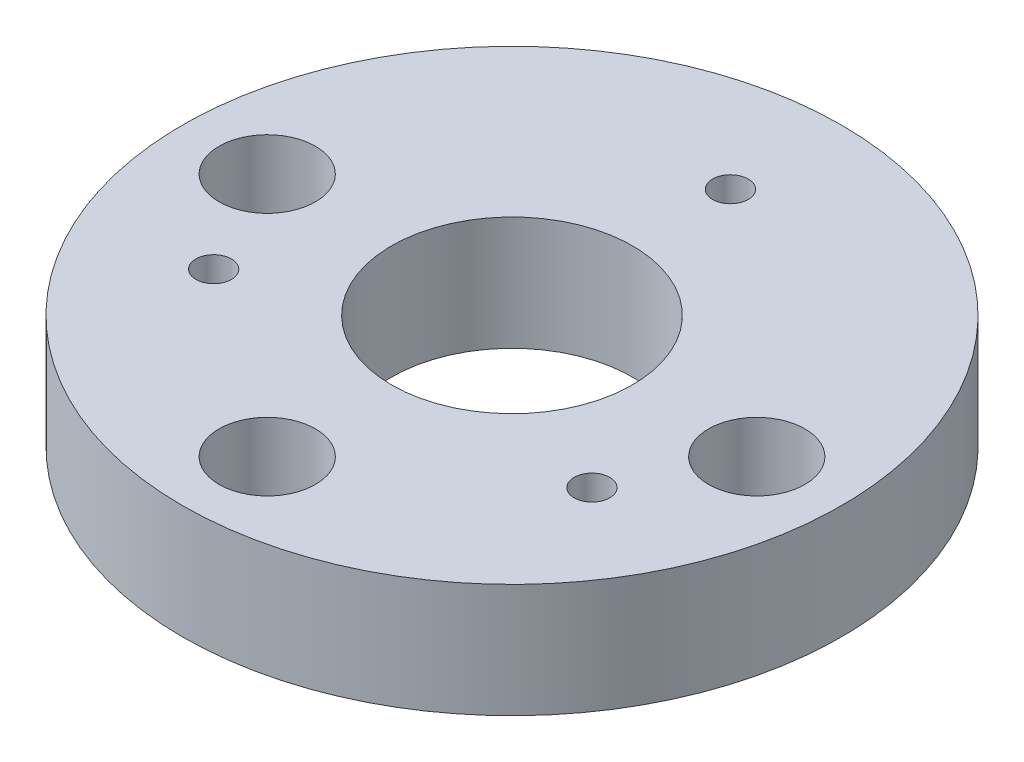
from build123d import *

# Parameters (mm, degrees)
SKETCH1_R               = 27.7876
SKETCH1_R_2             = 10.16
RING_DEPTH              = 9.5885
SKETCH2_R               = 1.5
ROBOT_SIDE1_HOLES_DEPTH = 10.5885
ROBOT_SIDE_CHAMFER_SIZE = 2.4
SKETCH3_R               = 1.838724863
TOOL_SIDE_HOLES_DEPTH   = 10.5885
SKETCH4_R               = 4.064
TOOL_SIDE_INSET_DEPTH   = 6


with BuildPart() as part:
    # Sketch1 → Ring (new body)
    with BuildSketch(Plane(origin=(0, 0, 0), x_dir=(1, 0, 0), z_dir=(0, 1, 0))):
        Circle(SKETCH1_R)
        Circle(SKETCH1_R_2, mode=Mode.SUBTRACT)
    extrude(amount=RING_DEPTH)

    # Sketch2 → Robot Side1 - Holes (cut, through all)
    with BuildSketch(Plane(origin=(0, 9.5885, 0), x_dir=(1, 0, 0), z_dir=(0, 1, 0))):
        with Locations((0, 18.415)):
            Circle(SKETCH2_R)
        with Locations((15.947857811, -9.2075)):
            Circle(SKETCH2_R)
        with Locations((-15.947857811, -9.2075)):
            Circle(SKETCH2_R)
    extrude(amount=-ROBOT_SIDE1_HOLES_DEPTH, mode=Mode.SUBTRACT)

    # Robot Side - Chamfer
    robot_side_chamfer_edges = [part.edges().sort_by_distance(p)[0] for p in [
        (-1.5, 0, -18.415),
        (14.447857811, 0, 9.2075),
        (-17.447857811, 0, 9.2075),
    ]]
    chamfer(robot_side_chamfer_edges, length=ROBOT_SIDE_CHAMFER_SIZE)

    # Sketch3 → Tool Side - Holes (cut, through all)
    with BuildSketch(Plane(origin=(0, 9.5885, 0), x_dir=(1, 0, 0), z_dir=(0, 1, 0))):
        with Locations((20.6375, 0)):
            Circle(SKETCH3_R)
        with Locations((0, -20.6375)):
            Circle(SKETCH3_R)
        with Locations((-20.6375, 0)):
            Circle(SKETCH3_R)
    extrude(amount=-TOOL_SIDE_HOLES_DEPTH, mode=Mode.SUBTRACT)

    # Sketch4 → Tool Side - Inset (cut)
    with BuildSketch(Plane(origin=(0, 9.5885, 0), x_dir=(1, 0, 0), z_dir=(0, 1, 0))):
        with Locations((-20.6375, 0)):
            Circle(SKETCH4_R)
        with Locations((0, -20.6375)):
            Circle(SKETCH4_R)
        with Locations((20.6375, 0)):
            Circle(SKETCH4_R)
    extrude(amount=-TOOL_SIDE_INSET_DEPTH, mode=Mode.SUBTRACT)


solid = part.part
